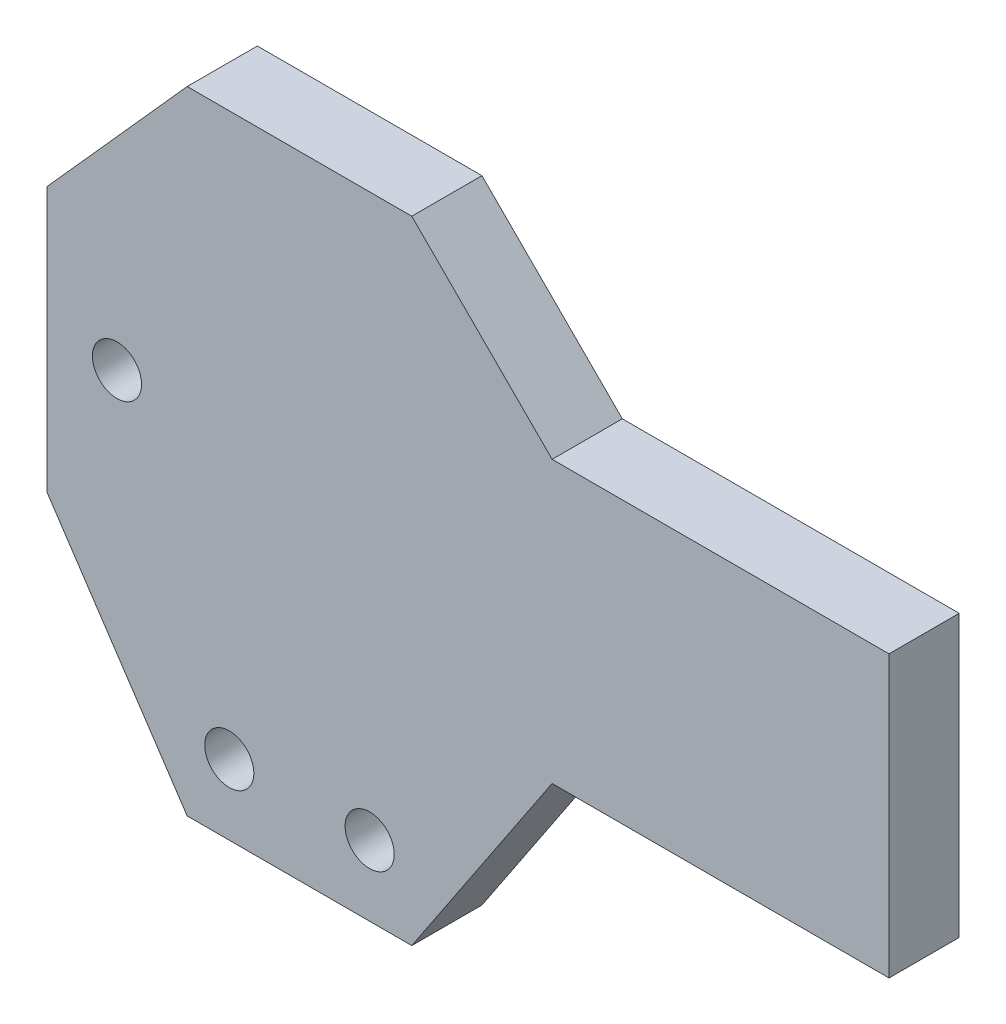
from build123d import *

# Parameters (mm, degrees)
SKETCH1_W           = 7.2
SKETCH1_H           = 10.8
SKETCH1_R           = 1.75
BOSS_EXTRUDE3_DEPTH = 5
SKETCH2_W           = 50
SKETCH2_H           = 20
BOSS_EXTRUDE4_DEPTH = 5


with BuildPart() as part:
    # Sketch1 → Boss-Extrude3 (new body)
    with BuildSketch(Plane.XY):
        with Locations((10.9, 2.5)):
            Rectangle(SKETCH1_W, SKETCH1_H)
        Polygon((-20, 22.5), (-30, 11.319660113), (-30, -7.5), (-20, -22.5), (-4, -22.5), (6, -7.5), (30, -7.5), (30, 12.5), (6, 12.5), (-4, 22.5), align=None)
        with Locations((-17, -17.5)):
            Circle(SKETCH1_R, mode=Mode.SUBTRACT)
        with Locations((-7, -17.5)):
            Circle(SKETCH1_R, mode=Mode.SUBTRACT)
        with Locations((-25, 2.5)):
            Circle(SKETCH1_R, mode=Mode.SUBTRACT)
        Polygon((-3.5, 7.9), (7.3, 7.9), (14.5, 7.9), (14.5, -2.9), (7.3, -2.9), (-3.5, -2.9), align=None, mode=Mode.SUBTRACT)
    extrude(amount=BOSS_EXTRUDE3_DEPTH)

    # Sketch2 → Boss-Extrude4 (add)
    with BuildSketch(Plane(origin=(0, 0, 0), x_dir=(-1, 0, 0), z_dir=(0, 0, -1))):
        with Locations((-5, 2.5)):
            Rectangle(SKETCH2_W, SKETCH2_H)
    extrude(amount=-BOSS_EXTRUDE4_DEPTH)


solid = part.part
